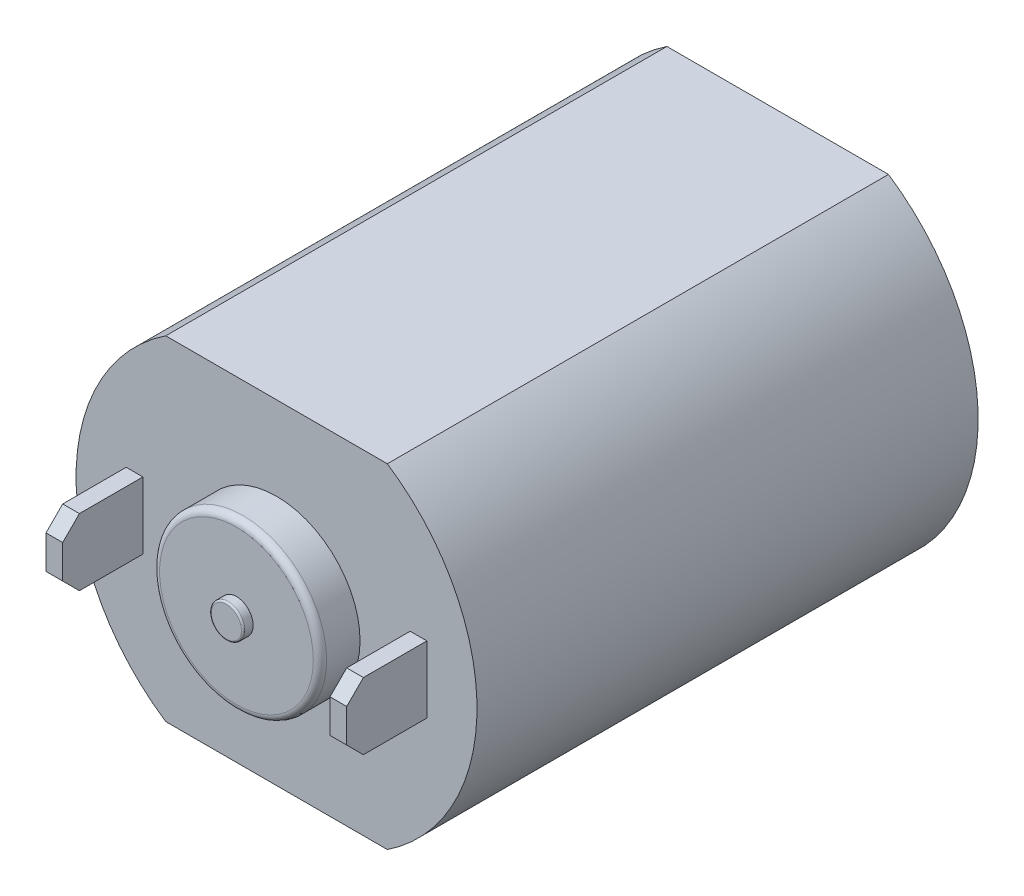
from build123d import *

# Parameters (mm, degrees)
SKETCH_1_R          = 6
EXTRUDE_1_DEPTH     = 15
CUT_EXTRUDE_1_DEPTH = 15
SKETCH_7_R          = 2.5
EXTRUDE_2_DEPTH     = 1.2
FILLET_1_R          = 0.2
SKETCH_8_R          = 0.5
EXTRUDE_3_DEPTH     = 0.3
FILLET_2_R          = 0.05
EXTRUDE_4_DEPTH     = 2.4
CHAMFER_1_SIZE      = 0.5
CHAMFER_2_SIZE      = 0.5
CHAMFER_3_SIZE      = 0.5
SKETCH_10_R         = 2
EXTRUDE_5_DEPTH     = 0.1


with BuildPart() as part:
    # 草图1 → 凸台-拉伸1 (new body)
    with BuildSketch(Plane.XY):
        Circle(SKETCH_1_R)
    extrude(amount=EXTRUDE_1_DEPTH)

    # 草图6 → 切除-拉伸1 (cut)
    with BuildSketch(Plane(origin=(0, 0, 0), x_dir=(-1, 0, 0), z_dir=(0, 0, -1))):
        with BuildLine():
            Line((-3.31662479, 5), (3.31662479, 5))
            ThreePointArc((3.31662479, 5), (0, 6), (-3.31662479, 5))
        make_face()
        with BuildLine():
            Line((-3.31662479, -5), (3.31662479, -5))
            ThreePointArc((3.31662479, -5), (0, -6), (-3.31662479, -5))
        make_face()
    extrude(amount=-CUT_EXTRUDE_1_DEPTH, mode=Mode.SUBTRACT)

    # 草图7 → 凸台-拉伸2 (add)
    with BuildSketch(Plane.XY.offset(15)):
        Circle(SKETCH_7_R)
    extrude(amount=EXTRUDE_2_DEPTH)

    # 圆角1
    fillet_1_edges = [part.edges().sort_by_distance(p)[0] for p in [
        (-2.5, 0, 16.2),
    ]]
    fillet(fillet_1_edges, radius=FILLET_1_R)

    # 草图8 → 凸台-拉伸3 (add)
    with BuildSketch(Plane.XY.offset(16.2)):
        Circle(SKETCH_8_R)
    extrude(amount=EXTRUDE_3_DEPTH)

    # 圆角2
    fillet_2_edges = [part.edges().sort_by_distance(p)[0] for p in [
        (-0.5, 0, 16.5),
    ]]
    fillet(fillet_2_edges, radius=FILLET_2_R)

    # 草图9 → 凸台-拉伸4 (add)
    with BuildSketch(Plane.XY.offset(15)):
        Polygon((4, 0), (4, 1), (4.5, 1), (4.5, -1), (4, -1), align=None)
        Polygon((-4, -1), (-4, 0), (-4, 1), (-4.5, 1), (-4.5, -1), align=None)
    extrude(amount=EXTRUDE_4_DEPTH)

    # 倒角1
    chamfer_1_edges = [part.edges().sort_by_distance(p)[0] for p in [
        (-4.25, 1, 17.4),
    ]]
    chamfer(chamfer_1_edges, length=CHAMFER_1_SIZE)

    # 倒角2
    chamfer_2_edges = [part.edges().sort_by_distance(p)[0] for p in [
        (-4.25, -1, 17.4),
    ]]
    chamfer(chamfer_2_edges, length=CHAMFER_2_SIZE)

    # 倒角3
    chamfer_3_edges = [part.edges().sort_by_distance(p)[0] for p in [
        (4.25, -1, 17.4),
        (4.25, 1, 17.4),
    ]]
    chamfer(chamfer_3_edges, length=CHAMFER_3_SIZE)

    # 草图10 → 凸台-拉伸5 (add)
    with BuildSketch(Plane(origin=(0, 0, 0), x_dir=(-1, 0, 0), z_dir=(0, 0, -1))):
        Circle(SKETCH_10_R)
    extrude(amount=EXTRUDE_5_DEPTH)


solid = part.part
